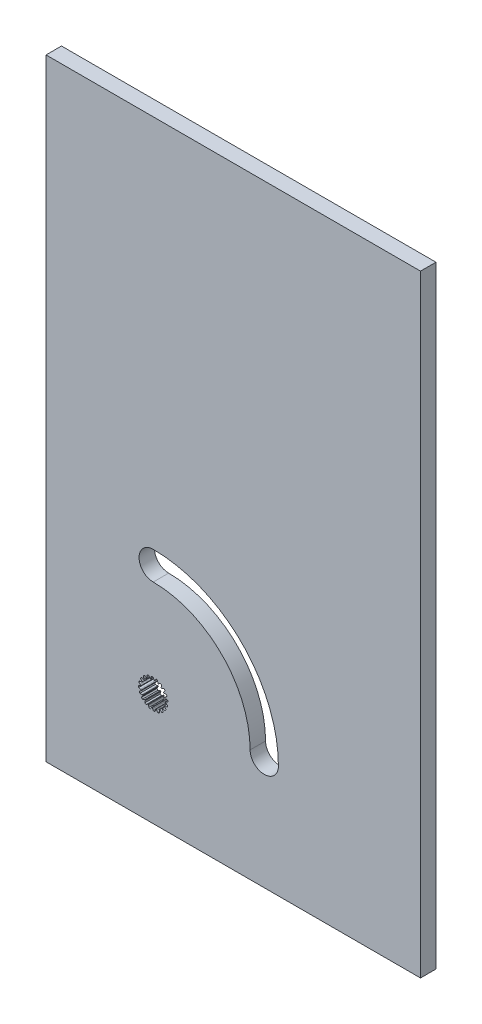
from build123d import *

# Parameters (mm, degrees)
IZIM1_W                     = 72.756230931
IZIM1_H                     = 118.946953667
Y_KSEKLIK_EKSTR_ZYON1_DEPTH = 3
KES_EKSTR_ZYON3_DEPTH       = 4
CUT_EXTRUDE1_DEPTH          = 4


with BuildPart() as part:
    # Çizim1 → Yükseklik-Ekstrüzyon1 (new body)
    with BuildSketch(Plane.XY):
        with Locations((-5.442235915, -33.122673723)):
            Rectangle(IZIM1_W, IZIM1_H)
    extrude(amount=Y_KSEKLIK_EKSTR_ZYON1_DEPTH)

    # Çizim4 → Kes-Ekstrüzyon3 (cut, through all)
    with BuildSketch(Plane(origin=(0, 0, 0), x_dir=(-1, 0, 0), z_dir=(0, 0, -1))):
        with BuildLine():
            Line((20.655005016, -68.253457169), (20.449524021, -67.970805458))
            ThreePointArc((20.449524021, -67.970805458), (20.301021516, -68.004254914), (20.154516787, -68.045585584))
            Line((20.154516787, -68.045585584), (20.108492616, -68.391990267))
            Line((20.108492616, -68.391990267), (20.11956599, -68.588571002))
            ThreePointArc((20.11956599, -68.588571002), (20.074637279, -68.607301226), (20.030106153, -68.62695801))
            Line((20.030106153, -68.62695801), (19.895263796, -68.483486258))
            Line((19.895263796, -68.483486258), (19.612495575, -68.278165626))
            ThreePointArc((19.612495575, -68.278165626), (19.48159775, -68.355867746), (19.355035352, -68.440448001))
            Line((19.355035352, -68.440448001), (19.418308698, -68.784120683))
            Line((19.418308698, -68.784120683), (19.489586891, -68.967658211))
            ThreePointArc((19.489586891, -68.967658211), (19.452645105, -68.999355448), (19.416367768, -69.031811035))
            Line((19.416367768, -69.031811035), (19.243789855, -68.93702987))
            Line((19.243789855, -68.93702987), (18.911413732, -68.829138531))
            ThreePointArc((18.911413732, -68.829138531), (18.810933778, -68.943487291), (18.716702521, -69.063037825))
            Line((18.716702521, -69.063037825), (18.883079748, -69.37033743))
            Line((18.883079748, -69.37033743), (19.007585553, -69.522865819))
            ThreePointArc((19.007585553, -69.522865819), (18.982246812, -69.564427322), (18.957774342, -69.606504734))
            Line((18.957774342, -69.606504734), (18.764354003, -69.569691997))
            Line((18.764354003, -69.569691997), (18.414905268, -69.569791106))
            ThreePointArc((18.414905268, -69.569791106), (18.354678863, -69.709593253), (18.302002759, -69.852411628))
            Line((18.302002759, -69.852411628), (18.555197705, -70.093257528))
            Line((18.555197705, -70.093257528), (18.720743626, -70.199846237))
            ThreePointArc((18.720743626, -70.199846237), (18.709488262, -70.247203677), (18.699216195, -70.294784083))
            Line((18.699216195, -70.294784083), (18.503886761, -70.319543262))
            Line((18.503886761, -70.319543262), (18.17157189, -70.427623118))
            ThreePointArc((18.17157189, -70.427623118), (18.157494415, -70.579193843), (18.151529767, -70.7313))
            Line((18.151529767, -70.7313), (18.466757947, -70.882116522))
            Line((18.466757947, -70.882116522), (18.657139197, -70.932331906))
            ThreePointArc((18.657139197, -70.932331906), (18.661068963, -70.980849606), (18.666002801, -71.029275504))
            Line((18.666002801, -71.029275504), (18.487884476, -71.113182997))
            Line((18.487884476, -71.113182997), (18.205232766, -71.318663992))
            ThreePointArc((18.205232766, -71.318663992), (18.238682221, -71.467166497), (18.280012892, -71.613671226))
            Line((18.280012892, -71.613671226), (18.626417574, -71.659695397))
            Line((18.626417574, -71.659695397), (18.822998309, -71.648622023))
            ThreePointArc((18.822998309, -71.648622023), (18.841728533, -71.693550734), (18.861385317, -71.73808186))
            Line((18.861385317, -71.73808186), (18.717913565, -71.872924217))
            Line((18.717913565, -71.872924217), (18.512592933, -72.155692438))
            ThreePointArc((18.512592933, -72.155692438), (18.590295054, -72.286590263), (18.674875308, -72.413152661))
            Line((18.674875308, -72.413152661), (19.01854799, -72.349879315))
            Line((19.01854799, -72.349879315), (19.202085518, -72.278601122))
            ThreePointArc((19.202085518, -72.278601122), (19.233782755, -72.315542908), (19.266238342, -72.351820245))
            Line((19.266238342, -72.351820245), (19.171457178, -72.524398158))
            Line((19.171457178, -72.524398158), (19.063565838, -72.856774281))
            ThreePointArc((19.063565838, -72.856774281), (19.177914598, -72.957254235), (19.297465133, -73.051485492))
            Line((19.297465133, -73.051485492), (19.604764737, -72.885108265))
            Line((19.604764737, -72.885108265), (19.757293126, -72.76060246))
            ThreePointArc((19.757293126, -72.76060246), (19.79885463, -72.785941201), (19.840932041, -72.810413671))
            Line((19.840932041, -72.810413671), (19.804119305, -73.00383401))
            Line((19.804119305, -73.00383401), (19.804218414, -73.353282745))
            ThreePointArc((19.804218414, -73.353282745), (19.944020561, -73.41350915), (20.086838935, -73.466185254))
            Line((20.086838935, -73.466185254), (20.327684835, -73.212990308))
            Line((20.327684835, -73.212990308), (20.434273545, -73.047444387))
            ThreePointArc((20.434273545, -73.047444387), (20.481630985, -73.058699751), (20.52921139, -73.068971818))
            Line((20.52921139, -73.068971818), (20.553970569, -73.264301252))
            Line((20.553970569, -73.264301252), (20.662050425, -73.596616123))
            ThreePointArc((20.662050425, -73.596616123), (20.813621151, -73.610693598), (20.965727308, -73.616658246))
            Line((20.965727308, -73.616658246), (21.116543829, -73.301430066))
            Line((21.116543829, -73.301430066), (21.166759213, -73.111048816))
            ThreePointArc((21.166759213, -73.111048816), (21.215276914, -73.10711905), (21.263702812, -73.102185212))
            Line((21.263702812, -73.102185212), (21.347610305, -73.280303537))
            Line((21.347610305, -73.280303537), (21.553091299, -73.562955247))
            ThreePointArc((21.553091299, -73.562955247), (21.701593804, -73.529505792), (21.848098533, -73.488175121))
            Line((21.848098533, -73.488175121), (21.894122704, -73.141770439))
            Line((21.894122704, -73.141770439), (21.88304933, -72.945189704))
            ThreePointArc((21.88304933, -72.945189704), (21.927978041, -72.92645948), (21.972509167, -72.906802696))
            Line((21.972509167, -72.906802696), (22.107351525, -73.050274448))
            Line((22.107351525, -73.050274448), (22.390119745, -73.25559508))
            ThreePointArc((22.390119745, -73.25559508), (22.52101757, -73.177892959), (22.647579968, -73.093312705))
            Line((22.647579968, -73.093312705), (22.584306622, -72.749640023))
            Line((22.584306622, -72.749640023), (22.51302843, -72.566102495))
            ThreePointArc((22.51302843, -72.566102495), (22.549970215, -72.534405258), (22.586247553, -72.501949671))
            Line((22.586247553, -72.501949671), (22.758825465, -72.596730835))
            Line((22.758825465, -72.596730835), (23.091201588, -72.704622175))
            ThreePointArc((23.091201588, -72.704622175), (23.191681542, -72.590273415), (23.285912799, -72.47072288))
            Line((23.285912799, -72.47072288), (23.119535572, -72.163423276))
            Line((23.119535572, -72.163423276), (22.995029767, -72.010894887))
            ThreePointArc((22.995029767, -72.010894887), (23.020368508, -71.969333383), (23.044840978, -71.927255972))
            Line((23.044840978, -71.927255972), (23.238261317, -71.964068708))
            Line((23.238261317, -71.964068708), (23.587710053, -71.963969599))
            ThreePointArc((23.587710053, -71.963969599), (23.647936457, -71.824167452), (23.700612562, -71.681349078))
            Line((23.700612562, -71.681349078), (23.447417615, -71.440503178))
            Line((23.447417615, -71.440503178), (23.281871694, -71.333914468))
            ThreePointArc((23.281871694, -71.333914468), (23.293127058, -71.286557028), (23.303399125, -71.238976623))
            Line((23.303399125, -71.238976623), (23.49872856, -71.214217444))
            Line((23.49872856, -71.214217444), (23.83104343, -71.106137588))
            ThreePointArc((23.83104343, -71.106137588), (23.845120905, -70.954566862), (23.851085553, -70.802460705))
            Line((23.851085553, -70.802460705), (23.535857373, -70.651644184))
            Line((23.535857373, -70.651644184), (23.345476123, -70.6014288))
            ThreePointArc((23.345476123, -70.6014288), (23.341546357, -70.552911099), (23.336612519, -70.504485201))
            Line((23.336612519, -70.504485201), (23.514730844, -70.420577708))
            Line((23.514730844, -70.420577708), (23.797382555, -70.215096714))
            ThreePointArc((23.797382555, -70.215096714), (23.763933099, -70.066594209), (23.722602429, -69.92008948))
            Line((23.722602429, -69.92008948), (23.376197746, -69.874065309))
            Line((23.376197746, -69.874065309), (23.179617011, -69.885138683))
            ThreePointArc((23.179617011, -69.885138683), (23.160886787, -69.840209972), (23.141230003, -69.795678846))
            Line((23.141230003, -69.795678846), (23.284701755, -69.660836488))
            Line((23.284701755, -69.660836488), (23.490022387, -69.378068268))
            ThreePointArc((23.490022387, -69.378068268), (23.412320267, -69.247170443), (23.327740012, -69.120608045))
            Line((23.327740012, -69.120608045), (22.98406733, -69.183881391))
            Line((22.98406733, -69.183881391), (22.800529802, -69.255159583))
            ThreePointArc((22.800529802, -69.255159583), (22.768832565, -69.218217798), (22.736376978, -69.18194046))
            Line((22.736376978, -69.18194046), (22.831158143, -69.009362548))
            Line((22.831158143, -69.009362548), (22.939049482, -68.676986425))
            ThreePointArc((22.939049482, -68.676986425), (22.824700722, -68.576506471), (22.705150188, -68.482275214))
            Line((22.705150188, -68.482275214), (22.397850583, -68.648652441))
            Line((22.397850583, -68.648652441), (22.245322194, -68.773158246))
            ThreePointArc((22.245322194, -68.773158246), (22.203760691, -68.747819505), (22.161683279, -68.723347035))
            Line((22.161683279, -68.723347035), (22.198496016, -68.529926696))
            Line((22.198496016, -68.529926696), (22.198396907, -68.18047796))
            ThreePointArc((22.198396907, -68.18047796), (22.05859476, -68.120251556), (21.915776385, -68.067575451))
            Line((21.915776385, -68.067575451), (21.674930485, -68.320770398))
            Line((21.674930485, -68.320770398), (21.568341776, -68.486316319))
            ThreePointArc((21.568341776, -68.486316319), (21.520984336, -68.475060955), (21.47340393, -68.464788888))
            Line((21.47340393, -68.464788888), (21.448644751, -68.269459453))
            Line((21.448644751, -68.269459453), (21.340564895, -67.937144583))
            ThreePointArc((21.340564895, -67.937144583), (21.18899417, -67.923067108), (21.036888013, -67.91710246))
            Line((21.036888013, -67.91710246), (20.886071491, -68.23233064))
            Line((20.886071491, -68.23233064), (20.835856107, -68.42271189))
            ThreePointArc((20.835856107, -68.42271189), (20.787338407, -68.426641656), (20.738912509, -68.431575494))
            Line((20.738912509, -68.431575494), (20.655005016, -68.253457169))
        make_face()
    extrude(amount=-KES_EKSTR_ZYON3_DEPTH, mode=Mode.SUBTRACT)

    # Sketch1 → Cut-Extrude1 (cut, through all)
    with BuildSketch(Plane.XY.offset(3)):
        with BuildLine():
            ThreePointArc((3.32869234, -70.766880353), (-3.797399674, -53.562972367), (-21.00130766, -46.436880353))
            ThreePointArc((-21.00130766, -46.436880353), (-23.75130766, -49.186880353), (-21.00130766, -51.936880353))
            ThreePointArc((-21.00130766, -51.936880353), (-7.68648697, -57.452059663), (-2.17130766, -70.766880353))
            ThreePointArc((-2.17130766, -70.766880353), (0.57869234, -73.516880353), (3.32869234, -70.766880353))
        make_face()
    extrude(amount=-CUT_EXTRUDE1_DEPTH, mode=Mode.SUBTRACT)


solid = part.part
